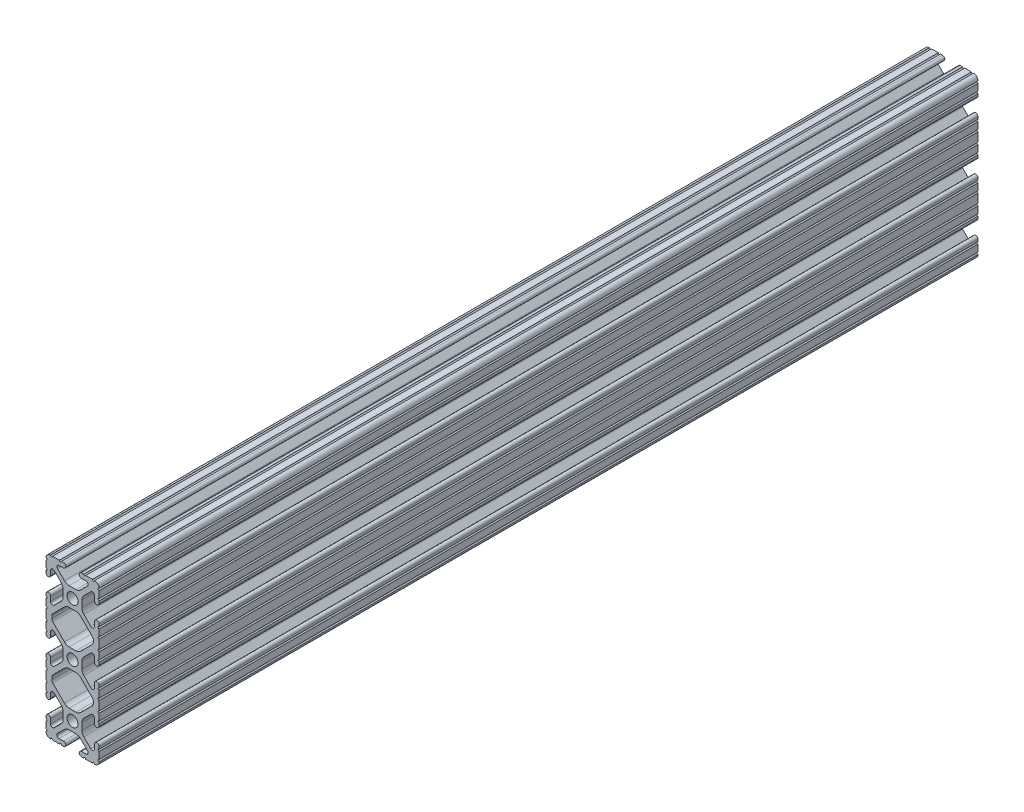
from build123d import *

# Parameters (mm, degrees)
SKETCH1_R           = 2.6035
BOSS_EXTRUDE1_DEPTH = 420.6875


with BuildPart() as part:
    # Sketch1 → Boss-Extrude1 (new body)
    with BuildSketch(Plane.XY):
        with BuildLine():
            Line((-6.3246, 38.1), (-9.5504, 38.1))
            ThreePointArc((-9.5504, 38.1), (-10.0584, 37.592), (-10.5664, 38.1))
            ThreePointArc((-10.5664, 38.1), (-12.082677406, 37.482677406), (-12.7, 35.9664))
            ThreePointArc((-12.7, 35.9664), (-12.192, 35.4584), (-12.7, 34.9504))
            Line((-12.7, 34.9504), (-12.7, 31.7246))
            ThreePointArc((-12.7, 31.7246), (-12.192, 31.2166), (-12.7, 30.7086))
            Line((-12.7, 30.7086), (-12.7, 29.702307889))
            ThreePointArc((-12.7, 29.702307889), (-11.5951, 28.597407889), (-10.4902, 29.702307889))
            Line((-10.4902, 29.702307889), (-10.4902, 31.874794456))
            ThreePointArc((-10.4902, 31.874794456), (-9.863006367, 32.813456061), (-8.75577951, 32.593214945))
            Line((-8.75577951, 32.593214945), (-5.43843597, 29.275871405))
            ThreePointArc((-5.43843597, 29.275871405), (-4.750182484, 28.245827272), (-4.5085, 27.030807374))
            Line((-4.5085, 27.030807374), (-4.5085, 23.769192626))
            ThreePointArc((-4.5085, 23.769192626), (-4.750182484, 22.554172728), (-5.43843597, 21.524128595))
            Line((-5.43843597, 21.524128595), (-8.75577951, 18.206785055))
            ThreePointArc((-8.75577951, 18.206785055), (-9.863006367, 17.986543939), (-10.4902, 18.925205544))
            Line((-10.4902, 18.925205544), (-10.4902, 21.097692111))
            ThreePointArc((-10.4902, 21.097692111), (-11.5951, 22.202592111), (-12.7, 21.097692111))
            Line((-12.7, 21.097692111), (-12.7, 20.0914))
            ThreePointArc((-12.7, 20.0914), (-12.192, 19.5834), (-12.7, 19.0754))
            Line((-12.7, 19.0754), (-12.7, 15.8496))
            ThreePointArc((-12.7, 15.8496), (-12.192, 15.3416), (-12.7, 14.8336))
            Line((-12.7, 14.8336), (-12.7, 10.5664))
            ThreePointArc((-12.7, 10.5664), (-12.192, 10.0584), (-12.7, 9.5504))
            Line((-12.7, 9.5504), (-12.7, 6.3246))
            ThreePointArc((-12.7, 6.3246), (-12.192, 5.8166), (-12.7, 5.3086))
            Line((-12.7, 5.3086), (-12.7, 4.302307889))
            ThreePointArc((-12.7, 4.302307889), (-11.5951, 3.197407889), (-10.4902, 4.302307889))
            Line((-10.4902, 4.302307889), (-10.4902, 6.474794456))
            ThreePointArc((-10.4902, 6.474794456), (-9.863006367, 7.413456061), (-8.75577951, 7.193214945))
            Line((-8.75577951, 7.193214945), (-5.43843597, 3.875871405))
            ThreePointArc((-5.43843597, 3.875871405), (-4.750182484, 2.845827272), (-4.5085, 1.630807374))
            Line((-4.5085, 1.630807374), (-4.5085, -1.630807374))
            ThreePointArc((-4.5085, -1.630807374), (-4.750182484, -2.845827272), (-5.43843597, -3.875871405))
            Line((-5.43843597, -3.875871405), (-8.75577951, -7.193214945))
            ThreePointArc((-8.75577951, -7.193214945), (-9.863006367, -7.413456061), (-10.4902, -6.474794456))
            Line((-10.4902, -6.474794456), (-10.4902, -4.302307889))
            ThreePointArc((-10.4902, -4.302307889), (-11.5951, -3.197407889), (-12.7, -4.302307889))
            Line((-12.7, -4.302307889), (-12.7, -5.3086))
            ThreePointArc((-12.7, -5.3086), (-12.192, -5.8166), (-12.7, -6.3246))
            Line((-12.7, -6.3246), (-12.7, -9.5504))
            ThreePointArc((-12.7, -9.5504), (-12.192, -10.0584), (-12.7, -10.5664))
            Line((-12.7, -10.5664), (-12.7, -14.8336))
            ThreePointArc((-12.7, -14.8336), (-12.192, -15.3416), (-12.7, -15.8496))
            Line((-12.7, -15.8496), (-12.7, -19.0754))
            ThreePointArc((-12.7, -19.0754), (-12.192, -19.5834), (-12.7, -20.0914))
            Line((-12.7, -20.0914), (-12.7, -21.097692111))
            ThreePointArc((-12.7, -21.097692111), (-11.5951, -22.202592111), (-10.4902, -21.097692111))
            Line((-10.4902, -21.097692111), (-10.4902, -18.925205544))
            ThreePointArc((-10.4902, -18.925205544), (-9.863006367, -17.986543939), (-8.75577951, -18.206785055))
            Line((-8.75577951, -18.206785055), (-5.43843597, -21.524128595))
            ThreePointArc((-5.43843597, -21.524128595), (-4.750182484, -22.554172728), (-4.5085, -23.769192626))
            Line((-4.5085, -23.769192626), (-4.5085, -27.030807374))
            ThreePointArc((-4.5085, -27.030807374), (-4.750182484, -28.245827272), (-5.43843597, -29.275871405))
            Line((-5.43843597, -29.275871405), (-8.75577951, -32.593214945))
            ThreePointArc((-8.75577951, -32.593214945), (-9.863006367, -32.813456061), (-10.4902, -31.874794456))
            Line((-10.4902, -31.874794456), (-10.4902, -29.702307889))
            ThreePointArc((-10.4902, -29.702307889), (-11.5951, -28.597407889), (-12.7, -29.702307889))
            Line((-12.7, -29.702307889), (-12.7, -30.7086))
            ThreePointArc((-12.7, -30.7086), (-12.192, -31.2166), (-12.7, -31.7246))
            Line((-12.7, -31.7246), (-12.7, -34.9504))
            ThreePointArc((-12.7, -34.9504), (-12.192, -35.4584), (-12.7, -35.9664))
            ThreePointArc((-12.7, -35.9664), (-12.082677406, -37.482677406), (-10.5664, -38.1))
            ThreePointArc((-10.5664, -38.1), (-10.0584, -37.592), (-9.5504, -38.1))
            Line((-9.5504, -38.1), (-6.3246, -38.1))
            ThreePointArc((-6.3246, -38.1), (-5.8166, -37.592), (-5.3086, -38.1))
            Line((-5.3086, -38.1), (-4.302307889, -38.1))
            ThreePointArc((-4.302307889, -38.1), (-3.197407889, -36.9951), (-4.302307889, -35.8902))
            Line((-4.302307889, -35.8902), (-6.474794456, -35.8902))
            ThreePointArc((-6.474794456, -35.8902), (-7.413456061, -35.263006367), (-7.193214945, -34.15577951))
            Line((-7.193214945, -34.15577951), (-3.875871405, -30.83843597))
            ThreePointArc((-3.875871405, -30.83843597), (-2.845827272, -30.150182484), (-1.630807374, -29.9085))
            Line((-1.630807374, -29.9085), (1.630807374, -29.9085))
            ThreePointArc((1.630807374, -29.9085), (2.845827272, -30.150182484), (3.875871405, -30.83843597))
            Line((3.875871405, -30.83843597), (7.193214945, -34.15577951))
            ThreePointArc((7.193214945, -34.15577951), (7.413456061, -35.263006367), (6.474794456, -35.8902))
            Line((6.474794456, -35.8902), (4.302307889, -35.8902))
            ThreePointArc((4.302307889, -35.8902), (3.197407889, -36.9951), (4.302307889, -38.1))
            Line((4.302307889, -38.1), (5.3086, -38.1))
            ThreePointArc((5.3086, -38.1), (5.8166, -37.592), (6.3246, -38.1))
            Line((6.3246, -38.1), (9.5504, -38.1))
            ThreePointArc((9.5504, -38.1), (10.0584, -37.592), (10.5664, -38.1))
            ThreePointArc((10.5664, -38.1), (12.082677406, -37.482677406), (12.7, -35.9664))
            ThreePointArc((12.7, -35.9664), (12.192, -35.4584), (12.7, -34.9504))
            Line((12.7, -34.9504), (12.7, -31.7246))
            ThreePointArc((12.7, -31.7246), (12.192, -31.2166), (12.7, -30.7086))
            Line((12.7, -30.7086), (12.7, -29.702307918))
            ThreePointArc((12.7, -29.702307918), (11.5951, -28.597407918), (10.4902, -29.702307918))
            Line((10.4902, -29.702307918), (10.4902, -31.874794456))
            ThreePointArc((10.4902, -31.874794456), (9.863006367, -32.813456061), (8.75577951, -32.593214945))
            Line((8.75577951, -32.593214945), (5.43843597, -29.275871405))
            ThreePointArc((5.43843597, -29.275871405), (4.750182484, -28.245827272), (4.5085, -27.030807374))
            Line((4.5085, -27.030807374), (4.5085, -23.769192626))
            ThreePointArc((4.5085, -23.769192626), (4.750182484, -22.554172728), (5.43843597, -21.524128595))
            Line((5.43843597, -21.524128595), (8.75577951, -18.206785055))
            ThreePointArc((8.75577951, -18.206785055), (9.863006367, -17.986543939), (10.4902, -18.925205544))
            Line((10.4902, -18.925205544), (10.4902, -21.097692058))
            ThreePointArc((10.4902, -21.097692058), (11.5951, -22.202592058), (12.7, -21.097692058))
            Line((12.7, -21.097692058), (12.7, -20.0914))
            ThreePointArc((12.7, -20.0914), (12.192, -19.5834), (12.7, -19.0754))
            Line((12.7, -19.0754), (12.7, -15.8496))
            ThreePointArc((12.7, -15.8496), (12.192, -15.3416), (12.7, -14.8336))
            Line((12.7, -14.8336), (12.7, -10.5664))
            ThreePointArc((12.7, -10.5664), (12.192, -10.0584), (12.7, -9.5504))
            Line((12.7, -9.5504), (12.7, -6.3246))
            ThreePointArc((12.7, -6.3246), (12.192, -5.8166), (12.7, -5.3086))
            Line((12.7, -5.3086), (12.7, -4.302307889))
            ThreePointArc((12.7, -4.302307889), (11.5951, -3.197407889), (10.4902, -4.302307889))
            Line((10.4902, -4.302307889), (10.4902, -6.474794456))
            ThreePointArc((10.4902, -6.474794456), (9.863006367, -7.413456061), (8.75577951, -7.193214945))
            Line((8.75577951, -7.193214945), (5.43843597, -3.875871405))
            ThreePointArc((5.43843597, -3.875871405), (4.750182484, -2.845827272), (4.5085, -1.630807374))
            Line((4.5085, -1.630807374), (4.5085, 1.630807374))
            ThreePointArc((4.5085, 1.630807374), (4.750182484, 2.845827272), (5.43843597, 3.875871405))
            Line((5.43843597, 3.875871405), (8.75577951, 7.193214945))
            ThreePointArc((8.75577951, 7.193214945), (9.863006367, 7.413456061), (10.4902, 6.474794456))
            Line((10.4902, 6.474794456), (10.4902, 4.302307889))
            ThreePointArc((10.4902, 4.302307889), (11.5951, 3.197407889), (12.7, 4.302307889))
            Line((12.7, 4.302307889), (12.7, 5.3086))
            ThreePointArc((12.7, 5.3086), (12.192, 5.8166), (12.7, 6.3246))
            Line((12.7, 6.3246), (12.7, 9.5504))
            ThreePointArc((12.7, 9.5504), (12.192, 10.0584), (12.7, 10.5664))
            Line((12.7, 10.5664), (12.7, 14.8336))
            ThreePointArc((12.7, 14.8336), (12.192, 15.3416), (12.7, 15.8496))
            Line((12.7, 15.8496), (12.7, 19.0754))
            ThreePointArc((12.7, 19.0754), (12.192, 19.5834), (12.7, 20.0914))
            Line((12.7, 20.0914), (12.7, 21.097692082))
            ThreePointArc((12.7, 21.097692082), (11.5951, 22.202592082), (10.4902, 21.097692082))
            Line((10.4902, 21.097692082), (10.4902, 18.925205544))
            ThreePointArc((10.4902, 18.925205544), (9.863006367, 17.986543939), (8.75577951, 18.206785055))
            Line((8.75577951, 18.206785055), (5.43843597, 21.524128595))
            ThreePointArc((5.43843597, 21.524128595), (4.750182484, 22.554172728), (4.5085, 23.769192626))
            Line((4.5085, 23.769192626), (4.5085, 27.030807374))
            ThreePointArc((4.5085, 27.030807374), (4.750182484, 28.245827272), (5.43843597, 29.275871405))
            Line((5.43843597, 29.275871405), (8.75577951, 32.593214945))
            ThreePointArc((8.75577951, 32.593214945), (9.863006367, 32.813456061), (10.4902, 31.874794456))
            Line((10.4902, 31.874794456), (10.4902, 29.702307889))
            ThreePointArc((10.4902, 29.702307889), (11.5951, 28.597407889), (12.7, 29.702307889))
            Line((12.7, 29.702307889), (12.7, 30.7086))
            ThreePointArc((12.7, 30.7086), (12.192, 31.2166), (12.7, 31.7246))
            Line((12.7, 31.7246), (12.7, 34.9504))
            ThreePointArc((12.7, 34.9504), (12.192, 35.4584), (12.7, 35.9664))
            ThreePointArc((12.7, 35.9664), (12.082677406, 37.482677406), (10.5664, 38.1))
            ThreePointArc((10.5664, 38.1), (10.0584, 37.592), (9.5504, 38.1))
            Line((9.5504, 38.1), (6.3246, 38.1))
            ThreePointArc((6.3246, 38.1), (5.8166, 37.592), (5.3086, 38.1))
            Line((5.3086, 38.1), (4.302307889, 38.1))
            ThreePointArc((4.302307889, 38.1), (3.197407889, 36.9951), (4.302307889, 35.8902))
            Line((4.302307889, 35.8902), (6.474794456, 35.8902))
            ThreePointArc((6.474794456, 35.8902), (7.413456061, 35.263006367), (7.193214945, 34.15577951))
            Line((7.193214945, 34.15577951), (3.875871405, 30.83843597))
            ThreePointArc((3.875871405, 30.83843597), (2.845827272, 30.150182484), (1.630807374, 29.9085))
            Line((1.630807374, 29.9085), (-1.630807374, 29.9085))
            ThreePointArc((-1.630807374, 29.9085), (-2.845827272, 30.150182484), (-3.875871405, 30.83843597))
            Line((-3.875871405, 30.83843597), (-7.193214945, 34.15577951))
            ThreePointArc((-7.193214945, 34.15577951), (-7.413456061, 35.263006367), (-6.474794456, 35.8902))
            Line((-6.474794456, 35.8902), (-4.302307889, 35.8902))
            ThreePointArc((-4.302307889, 35.8902), (-3.197407889, 36.9951), (-4.302307889, 38.1))
            Line((-4.302307889, 38.1), (-5.3086, 38.1))
            ThreePointArc((-5.3086, 38.1), (-5.8166, 37.592), (-6.3246, 38.1))
        make_face()
        with Locations((0, 25.4)):
            Circle(SKETCH1_R, mode=Mode.SUBTRACT)
        with Locations((0, -25.4)):
            Circle(SKETCH1_R, mode=Mode.SUBTRACT)
        Circle(SKETCH1_R, mode=Mode.SUBTRACT)
        with BuildLine():
            Line((-9.9314, 12.146268083), (-9.9314, 13.253731917))
            ThreePointArc((-9.9314, 13.253731917), (-9.811525488, 13.856381786), (-9.470151759, 14.367283676))
            Line((-9.470151759, 14.367283676), (-3.875871405, 19.96156403))
            ThreePointArc((-3.875871405, 19.96156403), (-2.845827272, 20.649817516), (-1.630807374, 20.8915))
            Line((-1.630807374, 20.8915), (1.630807374, 20.8915))
            ThreePointArc((1.630807374, 20.8915), (2.845827272, 20.649817516), (3.875871405, 19.96156403))
            Line((3.875871405, 19.96156403), (9.470151759, 14.367283676))
            ThreePointArc((9.470151759, 14.367283676), (9.811525488, 13.856381786), (9.9314, 13.253731917))
            Line((9.9314, 13.253731917), (9.9314, 12.146268083))
            ThreePointArc((9.9314, 12.146268083), (9.811525488, 11.543618214), (9.470151759, 11.032716324))
            Line((9.470151759, 11.032716324), (3.875871405, 5.43843597))
            ThreePointArc((3.875871405, 5.43843597), (2.845827272, 4.750182484), (1.630807374, 4.5085))
            Line((1.630807374, 4.5085), (-1.630807374, 4.5085))
            ThreePointArc((-1.630807374, 4.5085), (-2.845827272, 4.750182484), (-3.875871405, 5.43843597))
            Line((-3.875871405, 5.43843597), (-9.470151759, 11.032716324))
            ThreePointArc((-9.470151759, 11.032716324), (-9.811525488, 11.543618214), (-9.9314, 12.146268083))
        make_face(mode=Mode.SUBTRACT)
        with BuildLine():
            Line((-9.9314, -13.253731917), (-9.9314, -12.146268083))
            ThreePointArc((-9.9314, -12.146268083), (-9.811525488, -11.543618214), (-9.470151759, -11.032716324))
            Line((-9.470151759, -11.032716324), (-3.875871405, -5.43843597))
            ThreePointArc((-3.875871405, -5.43843597), (-2.845827272, -4.750182484), (-1.630807374, -4.5085))
            Line((-1.630807374, -4.5085), (1.630807374, -4.5085))
            ThreePointArc((1.630807374, -4.5085), (2.845827272, -4.750182484), (3.875871405, -5.43843597))
            Line((3.875871405, -5.43843597), (9.470151759, -11.032716324))
            ThreePointArc((9.470151759, -11.032716324), (9.811525488, -11.543618214), (9.9314, -12.146268083))
            Line((9.9314, -12.146268083), (9.9314, -13.253731917))
            ThreePointArc((9.9314, -13.253731917), (9.811525488, -13.856381786), (9.470151759, -14.367283676))
            Line((9.470151759, -14.367283676), (3.875871405, -19.96156403))
            ThreePointArc((3.875871405, -19.96156403), (2.845827272, -20.649817516), (1.630807374, -20.8915))
            Line((1.630807374, -20.8915), (-1.630807374, -20.8915))
            ThreePointArc((-1.630807374, -20.8915), (-2.845827272, -20.649817516), (-3.875871405, -19.96156403))
            Line((-3.875871405, -19.96156403), (-9.470151759, -14.367283676))
            ThreePointArc((-9.470151759, -14.367283676), (-9.811525488, -13.856381786), (-9.9314, -13.253731917))
        make_face(mode=Mode.SUBTRACT)
    extrude(amount=-BOSS_EXTRUDE1_DEPTH)


solid = part.part
